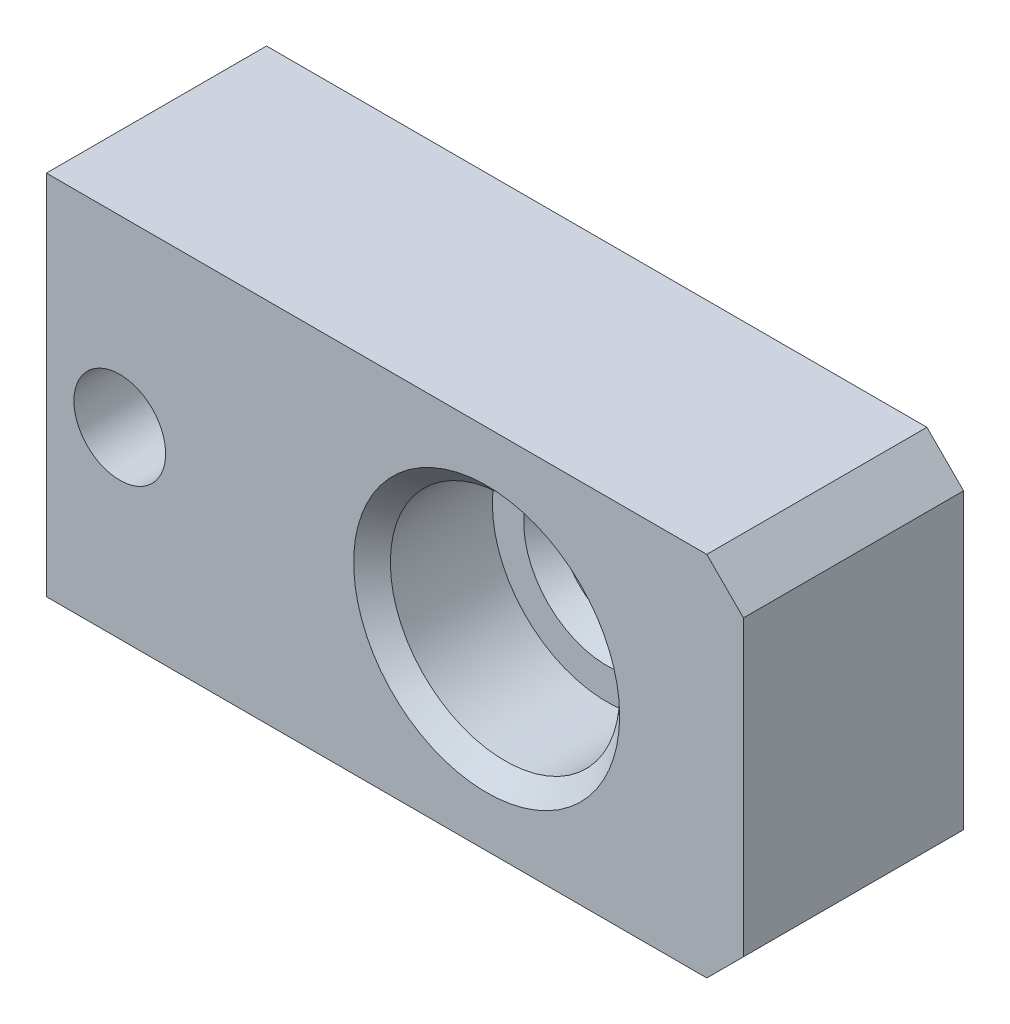
from build123d import *

# Parameters (mm, degrees)
SKETCH1_W      = 25.4
SKETCH1_H      = 12.7
SKETCH1_R      = 1.27
EXTRUDE1_DEPTH = 7.62
CHAMFER1_SIZE  = 1.27


with BuildPart() as part:
    # Sketch1 → Extrude1 (new body)
    with BuildSketch(Plane.XY):
        with Locations((12.7, 6.35)):
            Rectangle(SKETCH1_W, SKETCH1_H)
        with Locations((16.51, 6.35)):
            Circle(SKETCH1_R, mode=Mode.SUBTRACT)
    extrude(amount=EXTRUDE1_DEPTH)

    # Chamfer1
    chamfer1_edges = [part.edges().sort_by_distance(p)[0] for p in [
        (0, 6.35, 7.62),
        (0, 6.35, 0),
        (0, 12.7, 3.81),
        (25.4, 12.7, 3.81),
        (25.4, 0, 3.81),
        (0, 0, 3.81),
    ]]
    chamfer(chamfer1_edges, length=CHAMFER1_SIZE)

    # Sketch2 → CBORE for #8 Socket Head Cap Screw1 (revolve, cut)
    with BuildSketch(Plane(origin=(16.51, 6.35, 7.62), x_dir=(0, -1, 0), z_dir=(1, 0, 0))):
        Polygon((0, 0), (0, 7.62), (2.8829, 7.62), (2.2479, 6.985), (2.2479, 4.8006), (2.8829, 4.1656), (3.96875, 4.1656), (3.96875, 0.635), (4.60375, 0), align=None)
    revolve(axis=Axis((16.51, 6.35, 13.97), (0, 0, -1)), mode=Mode.SUBTRACT)

    # Sketch4 → CBORE for #4 Socket Head Cap Screw1 (revolve, cut)
    with BuildSketch(Plane(origin=(3.81, 6.35, 0), x_dir=(0, 1, 0), z_dir=(1, 0, 0))):
        Polygon((0, 0), (0, 7.62), (1.5875, 7.62), (1.5875, 1.524), (1.6002, 1.524), (1.6002, 0.3048), (1.905, 0), align=None)
    revolve(axis=Axis((3.81, 6.35, -6.35), (0, 0, 1)), mode=Mode.SUBTRACT)


solid = part.part
